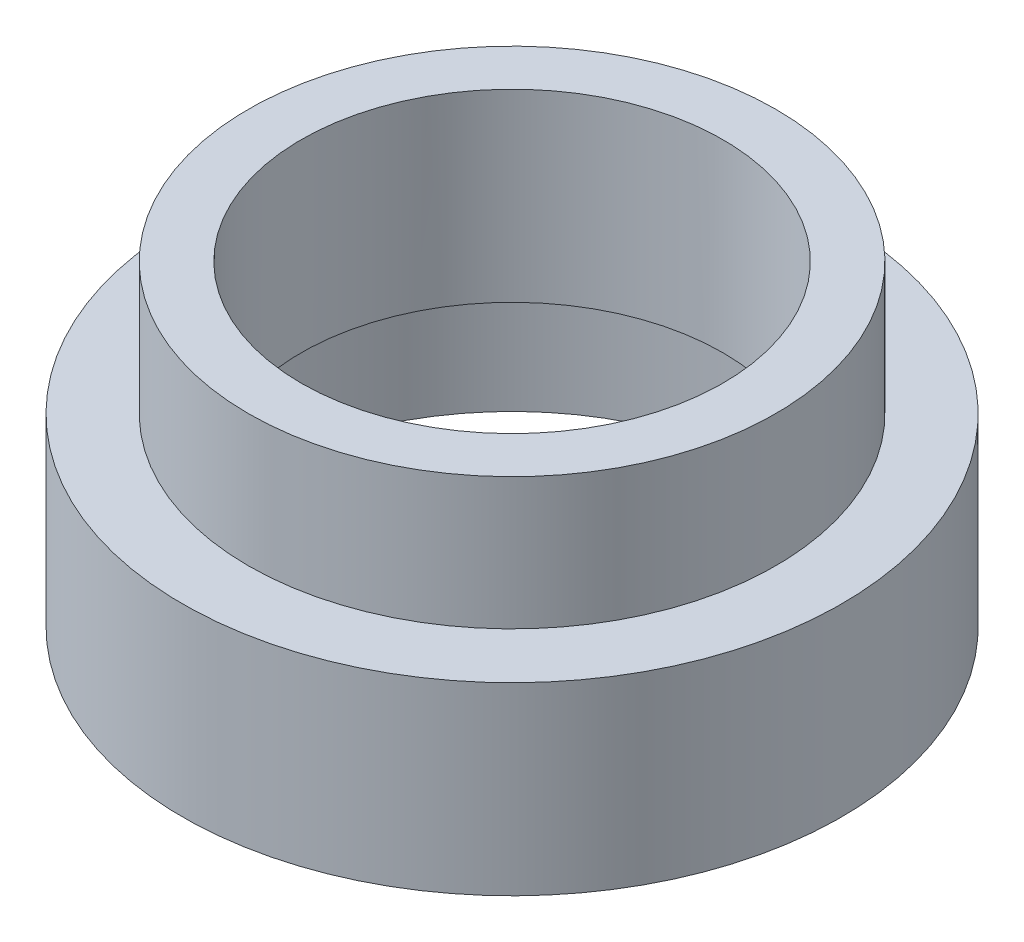
from build123d import *

# Parameters (mm, degrees)
SKETCH1_R           = 5
BOSS_EXTRUDE1_DEPTH = 2.5
SKETCH2_R           = 6.25
BOSS_EXTRUDE2_DEPTH = 3.5
SKETCH3_R           = 4
CUT_EXTRUDE1_DEPTH  = 7.5
SKETCH4_R           = 5
CUT_EXTRUDE2_DEPTH  = 2.5


with BuildPart() as part:
    # Sketch1 → Boss-Extrude1 (new body)
    with BuildSketch(Plane(origin=(0, 0, 0), x_dir=(1, 0, 0), z_dir=(0, 1, 0))):
        Circle(SKETCH1_R)
    extrude(amount=BOSS_EXTRUDE1_DEPTH)

    # Sketch2 → Boss-Extrude2 (add)
    with BuildSketch(Plane.XZ):
        Circle(SKETCH2_R)
    extrude(amount=BOSS_EXTRUDE2_DEPTH)

    # Sketch3 → Cut-Extrude1 (cut)
    with BuildSketch(Plane(origin=(0, 2.5, 0), x_dir=(1, 0, 0), z_dir=(0, 1, 0))):
        Circle(SKETCH3_R)
    extrude(amount=-CUT_EXTRUDE1_DEPTH, mode=Mode.SUBTRACT)

    # Sketch4 → Cut-Extrude2 (cut)
    with BuildSketch(Plane.XZ.offset(3.5)):
        Circle(SKETCH4_R)
    extrude(amount=-CUT_EXTRUDE2_DEPTH, mode=Mode.SUBTRACT)


solid = part.part
